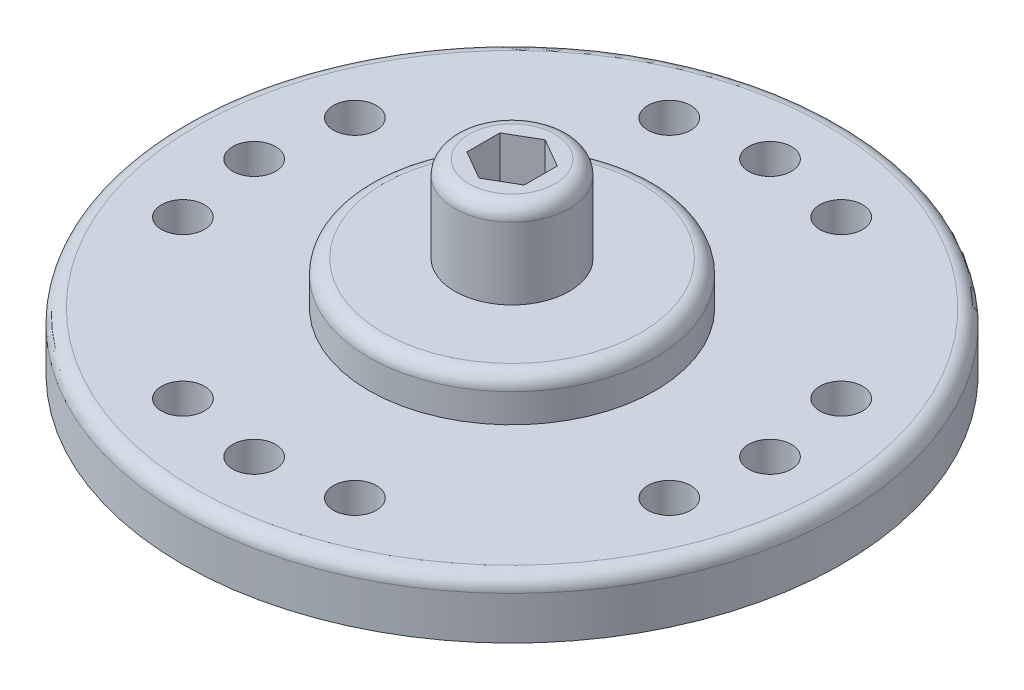
from build123d import *

# Parameters (mm, degrees)
CROQUIS1_R              = 11.5
SALIENTE_EXTRUIR1_DEPTH = 2
CROQUIS1_9_R            = 0.75
CORTAR_EXTRUIR2_DEPTH   = 3
MATRIZC2_COUNT          = 4
SALIENTE_EXTRUIR2_START = 2
CROQUIS1_11_R           = 5
SALIENTE_EXTRUIR2_DEPTH = 1.5
SALIENTE_EXTRUIR3_START = 3.5
CROQUIS1_12_R           = 2
SALIENTE_EXTRUIR3_DEPTH = 3
REDONDEO1_R             = 0.5
CROQUIS1_13_R           = 5
CROQUIS1_13_R_2         = 2
SALIENTE_EXTRUIR4_DEPTH = 1


with BuildPart() as part:
    # Croquis1 → Saliente-Extruir1 (new body)
    with BuildSketch(Plane(origin=(0, 0, 0), x_dir=(1, 0, 0), z_dir=(0, 1, 0))):
        with Locations((0, 13.3)):
            Circle(CROQUIS1_R)
    extrude(amount=SALIENTE_EXTRUIR1_DEPTH)

    # Croquis1_9 → Cortar-Extruir2 (cut)
    with BuildSketch(Plane(origin=(0, 0, 0), x_dir=(1, 0, 0), z_dir=(0, 1, 0))):
        with Locations((0, 22.3)):
            Circle(CROQUIS1_9_R)
        with Locations((3, 21.785281374)):
            Circle(CROQUIS1_9_R)
        with Locations((-3, 21.785281374)):
            Circle(CROQUIS1_9_R)
    cortar_extruir2 = extrude(amount=CORTAR_EXTRUIR2_DEPTH, mode=Mode.SUBTRACT)

    # MatrizC2: Cortar-Extruir2 ×4 about axis
    matrizc2_axis = Axis((0, 0, -13.3), (0, 1, 0))
    for i in range(1, MATRIZC2_COUNT):
        add(cortar_extruir2.rotate(matrizc2_axis, i * 360 / MATRIZC2_COUNT), mode=Mode.SUBTRACT)

    # Croquis1_11 → Saliente-Extruir2 (add)
    with BuildSketch(Plane(origin=(0, 0, 0), x_dir=(1, 0, 0), z_dir=(0, 1, 0)).offset(SALIENTE_EXTRUIR2_START)):
        with Locations((0, 13.3)):
            Circle(CROQUIS1_11_R)
    extrude(amount=SALIENTE_EXTRUIR2_DEPTH)

    # Croquis1_12 → Saliente-Extruir3 (add)
    with BuildSketch(Plane(origin=(0, 0, 0), x_dir=(1, 0, 0), z_dir=(0, 1, 0)).offset(SALIENTE_EXTRUIR3_START)):
        with Locations((0, 13.3)):
            Circle(CROQUIS1_12_R)
        Polygon((1, 12.722649731), (1, 13.877350269), (0, 14.454700538), (-1, 13.877350269), (-1, 12.722649731), (0, 12.145299462), align=None, mode=Mode.SUBTRACT)
    extrude(amount=SALIENTE_EXTRUIR3_DEPTH)

    # Redondeo1
    redondeo1_edges = [part.edges().sort_by_distance(p)[0] for p in [
        (-11.5, 2, -13.3),
        (-5, 3.5, -13.3),
        (-2, 6.5, -13.3),
    ]]
    fillet(redondeo1_edges, radius=REDONDEO1_R)

    # Croquis1_13 → Saliente-Extruir4 (add)
    with BuildSketch(Plane(origin=(0, 0, 0), x_dir=(1, 0, 0), z_dir=(0, 1, 0))):
        with Locations((0, 13.3)):
            Circle(CROQUIS1_13_R)
        with Locations((0, 13.3)):
            Circle(CROQUIS1_13_R_2, mode=Mode.SUBTRACT)
    extrude(amount=-SALIENTE_EXTRUIR4_DEPTH)


solid = part.part
